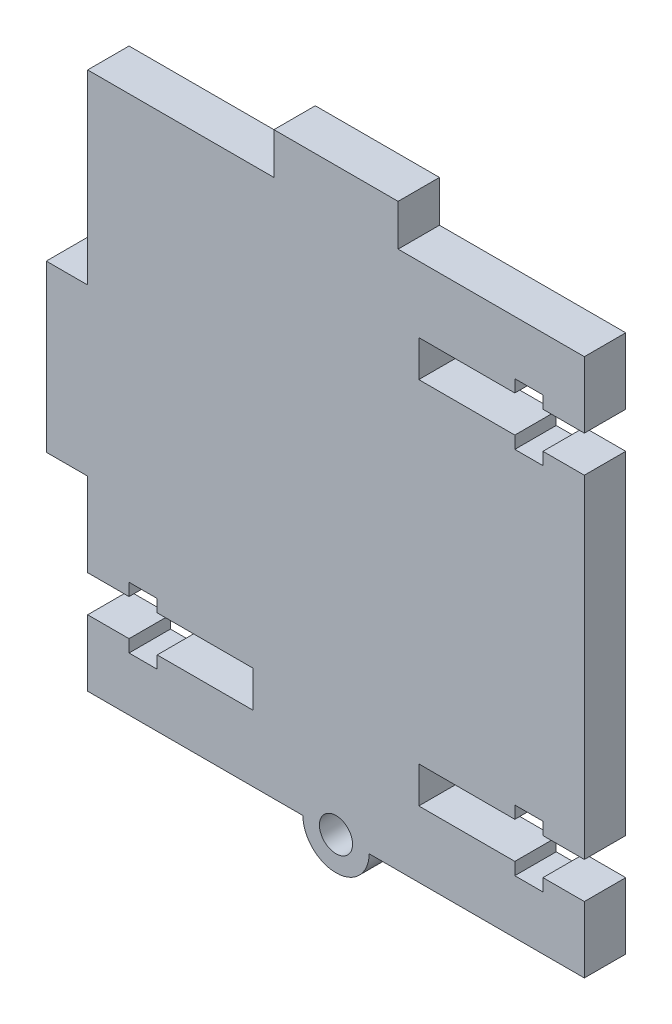
from build123d import *

# Parameters (mm, degrees)
BOSS_EXTRUDE1_DEPTH = 5
CUT_EXTRUDE1_DEPTH  = 5
SKETCH10_R          = 4
SKETCH10_R_2        = 2
BOSS_EXTRUDE3_DEPTH = 5
SKETCH11_R          = 2
CUT_EXTRUDE3_DEPTH  = 5


with BuildPart() as part:
    # Sketch1 → Boss-Extrude1 (new body)
    with BuildSketch(Plane.XY):
        Polygon((7.5, 32.5), (7.5, 37.5), (-7.5, 37.5), (-7.5, 32.5), (-30, 32.5), (-30, 10), (-35, 10), (-35, -10), (-30, -10), (-30, -32.5), (30, -32.5), (30, 32.5), align=None)
    extrude(amount=BOSS_EXTRUDE1_DEPTH)

    # Sketch3 → Cut-Extrude1 (cut)
    with BuildSketch(Plane.XY.offset(5)):
        Polygon((30, 24.5), (25, 24.5), (25, 26), (21.6, 26), (21.6, 24.5), (10, 24.5), (10, 20.1), (21.6, 20.1), (21.6, 18.6), (25, 18.6), (25, 20.1), (30, 20.1), align=None)
        Polygon((30, -24.5), (30, -20.1), (25, -20.1), (25, -18.6), (21.6, -18.6), (21.6, -20.1), (10, -20.1), (10, -24.5), (21.6, -24.5), (21.6, -26), (25, -26), (25, -24.5), align=None)
        Polygon((-30, -24.5), (-25, -24.5), (-25, -26), (-21.6, -26), (-21.6, -24.5), (-10, -24.5), (-10, -20.1), (-21.6, -20.1), (-21.6, -18.6), (-25, -18.6), (-25, -20.1), (-30, -20.1), align=None)
    extrude(amount=-CUT_EXTRUDE1_DEPTH, mode=Mode.SUBTRACT)

    # Sketch10 → Boss-Extrude3 (add)
    with BuildSketch(Plane.XY.offset(5)):
        with Locations((0, -32.5)):
            Circle(SKETCH10_R)
        with Locations((0, -32.5)):
            Circle(SKETCH10_R_2, mode=Mode.SUBTRACT)
    extrude(amount=-BOSS_EXTRUDE3_DEPTH)

    # Sketch11 → Cut-Extrude3 (cut)
    with BuildSketch(Plane.XY.offset(5)):
        with Locations((0, -32.5)):
            Circle(SKETCH11_R)
    extrude(amount=-CUT_EXTRUDE3_DEPTH, mode=Mode.SUBTRACT)


solid = part.part
